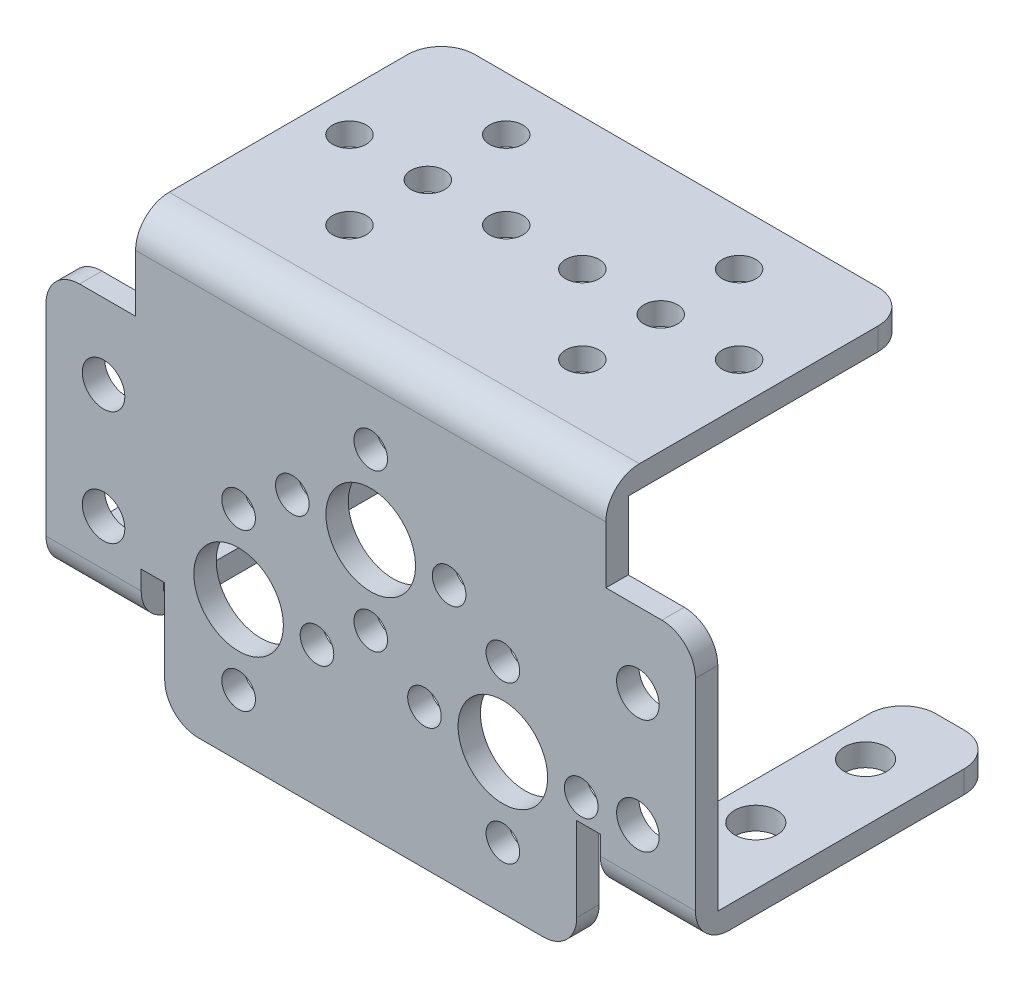
from build123d import *

# Parameters (mm, degrees)
EXTRUDE_1_DEPTH     = 2
SKETCH_2_W          = 42
SKETCH_2_H          = 2
EXTRUDE_2_DEPTH     = 25.3
SKETCH_3_W          = 8.5
SKETCH_3_H          = 2
EXTRUDE_3_DEPTH     = 25
FILLET_3_R          = 3
FILLET_4_R          = 3
FILLET_5_R          = 3
FILLET_6_R          = 3
FILLET_7_R          = 3
FILLET_8_R          = 3
FILLET_9_R          = 3
FILLET_10_R         = 3
FILLET_11_R         = 3
FILLET_12_R         = 3
SKETCH_5_R          = 1.5
SKETCH_5_R_2        = 4
SKETCH_5_R_3        = 1.9
CUT_EXTRUDE_5_DEPTH = 2
SKETCH_9_R          = 1.9
CUT_EXTRUDE_6_DEPTH = 2
SKETCH_10_R         = 1.5
CUT_EXTRUDE_7_DEPTH = 2
FILLET_13_R         = 3
FILLET_14_R         = 3
FILLET_15_R         = 3


with BuildPart() as part:
    # 草图1 → 凸台-拉伸1 (new body)
    with BuildSketch(Plane.XY):
        Polygon((0, 0), (42, 0), (42, -8.1), (50, -8.1), (50, -32.1), (41.5, -32.1), (41.5, -27.4), (39.4, -27.4), (39.4, -37.9), (2.6, -37.9), (2.6, -27.4), (0.5, -27.4), (0.5, -32.1), (-8, -32.1), (-8, -8.1), (0, -8.1), align=None)
    extrude(amount=EXTRUDE_1_DEPTH)

    # 草图2 → 凸台-拉伸2 (add)
    with BuildSketch(Plane(origin=(0, 0, 0), x_dir=(-1, 0, 0), z_dir=(0, 0, -1))):
        with Locations((-21, -1)):
            Rectangle(SKETCH_2_W, SKETCH_2_H)
    extrude(amount=EXTRUDE_2_DEPTH)

    # 草图3 → 凸台-拉伸3 (add)
    with BuildSketch(Plane(origin=(0, 0, 0), x_dir=(-1, 0, 0), z_dir=(0, 0, -1))):
        with Locations((-45.75, -31.1)):
            Rectangle(SKETCH_3_W, SKETCH_3_H)
        with Locations((3.75, -31.1)):
            Rectangle(SKETCH_3_W, SKETCH_3_H)
    extrude(amount=EXTRUDE_3_DEPTH)

    # 圆角3
    fillet_3_edges = [part.edges().sort_by_distance(p)[0] for p in [
        (42, -1, -25.3),
    ]]
    fillet(fillet_3_edges, radius=FILLET_3_R)

    # 圆角4
    fillet_4_edges = [part.edges().sort_by_distance(p)[0] for p in [
        (41.5, -31.1, -25),
    ]]
    fillet(fillet_4_edges, radius=FILLET_4_R)

    # 圆角5
    fillet_5_edges = [part.edges().sort_by_distance(p)[0] for p in [
        (0, -1, -25.3),
    ]]
    fillet(fillet_5_edges, radius=FILLET_5_R)

    # 圆角6
    fillet_6_edges = [part.edges().sort_by_distance(p)[0] for p in [
        (50, -31.1, -25),
    ]]
    fillet(fillet_6_edges, radius=FILLET_6_R)

    # 圆角7
    fillet_7_edges = [part.edges().sort_by_distance(p)[0] for p in [
        (-8, -31.1, -25),
    ]]
    fillet(fillet_7_edges, radius=FILLET_7_R)

    # 圆角8
    fillet_8_edges = [part.edges().sort_by_distance(p)[0] for p in [
        (0.5, -31.1, -25),
    ]]
    fillet(fillet_8_edges, radius=FILLET_8_R)

    # 圆角9
    fillet_9_edges = [part.edges().sort_by_distance(p)[0] for p in [
        (39.4, -37.9, 1),
    ]]
    fillet(fillet_9_edges, radius=FILLET_9_R)

    # 圆角10
    fillet_10_edges = [part.edges().sort_by_distance(p)[0] for p in [
        (2.6, -37.9, 1),
    ]]
    fillet(fillet_10_edges, radius=FILLET_10_R)

    # 圆角11
    fillet_11_edges = [part.edges().sort_by_distance(p)[0] for p in [
        (50, -8.1, 1),
    ]]
    fillet(fillet_11_edges, radius=FILLET_11_R)

    # 圆角12
    fillet_12_edges = [part.edges().sort_by_distance(p)[0] for p in [
        (-8, -8.1, 1),
    ]]
    fillet(fillet_12_edges, radius=FILLET_12_R)

    # 草图5 → 切除-拉伸5 (cut)
    with BuildSketch(Plane(origin=(0, 0, 0), x_dir=(-1, 0, 0), z_dir=(0, 0, -1))):
        with Locations((-32.8, -32.4)):
            Circle(SKETCH_5_R)
        with Locations((-32.8, -25.4)):
            Circle(SKETCH_5_R_2)
        with Locations((-25.8, -25.4)):
            Circle(SKETCH_5_R)
        with Locations((-32.8, -18.4)):
            Circle(SKETCH_5_R)
        with Locations((-39.8, -25.4)):
            Circle(SKETCH_5_R)
        with Locations((-21, -14.9)):
            Circle(SKETCH_5_R_2)
        with Locations((-14, -14.9)):
            Circle(SKETCH_5_R)
        with Locations((-21, -7.9)):
            Circle(SKETCH_5_R)
        with Locations((-21, -21.9)):
            Circle(SKETCH_5_R)
        with Locations((-44.86, -25)):
            Circle(SKETCH_5_R_3)
        with Locations((-44.86, -14.8)):
            Circle(SKETCH_5_R_3)
        with Locations((-28, -14.9)):
            Circle(SKETCH_5_R)
        with Locations((-9.2, -32.4)):
            Circle(SKETCH_5_R)
        with Locations((-9.2, -18.4)):
            Circle(SKETCH_5_R)
        with Locations((-16.2, -25.4)):
            Circle(SKETCH_5_R)
        with Locations((-9.2, -25.4)):
            Circle(SKETCH_5_R_2)
        with Locations((2.86, -25)):
            Circle(SKETCH_5_R_3)
        with Locations((2.86, -14.8)):
            Circle(SKETCH_5_R_3)
    extrude(amount=-CUT_EXTRUDE_5_DEPTH, mode=Mode.SUBTRACT)

    # 草图9 → 切除-拉伸6 (cut)
    with BuildSketch(Plane(origin=(0, -30.1, 0), x_dir=(1, 0, 0), z_dir=(0, 1, 0))):
        with Locations((44.85, 18.34)):
            Circle(SKETCH_9_R)
        with Locations((44.85, 8.54)):
            Circle(SKETCH_9_R)
        with Locations((-3.15, 8.54)):
            Circle(SKETCH_9_R)
        with Locations((-3.15, 18.34)):
            Circle(SKETCH_9_R)
    extrude(amount=-CUT_EXTRUDE_6_DEPTH, mode=Mode.SUBTRACT)

    # 草图10 → 切除-拉伸7 (cut)
    with BuildSketch(Plane.XZ.offset(2)):
        with Locations((10.6, -20.5)):
            Circle(SKETCH_10_R)
        with Locations((10.6, -13.5)):
            Circle(SKETCH_10_R)
        with Locations((10.6, -6.5)):
            Circle(SKETCH_10_R)
        with Locations((17.6, -13.5)):
            Circle(SKETCH_10_R)
        with Locations((3.6, -13.5)):
            Circle(SKETCH_10_R)
        with Locations((31.4, -20.5)):
            Circle(SKETCH_10_R)
        with Locations((24.4, -13.5)):
            Circle(SKETCH_10_R)
        with Locations((31.4, -13.5)):
            Circle(SKETCH_10_R)
        with Locations((38.4, -13.5)):
            Circle(SKETCH_10_R)
        with Locations((31.4, -6.5)):
            Circle(SKETCH_10_R)
    extrude(amount=-CUT_EXTRUDE_7_DEPTH, mode=Mode.SUBTRACT)

    # 圆角13
    fillet_13_edges = [part.edges().sort_by_distance(p)[0] for p in [
        (21, 0, 2),
    ]]
    fillet(fillet_13_edges, radius=FILLET_13_R)

    # 圆角14
    fillet_14_edges = [part.edges().sort_by_distance(p)[0] for p in [
        (45.75, -32.1, 2),
    ]]
    fillet(fillet_14_edges, radius=FILLET_14_R)

    # 圆角15
    fillet_15_edges = [part.edges().sort_by_distance(p)[0] for p in [
        (-3.75, -32.1, 2),
    ]]
    fillet(fillet_15_edges, radius=FILLET_15_R)


solid = part.part
